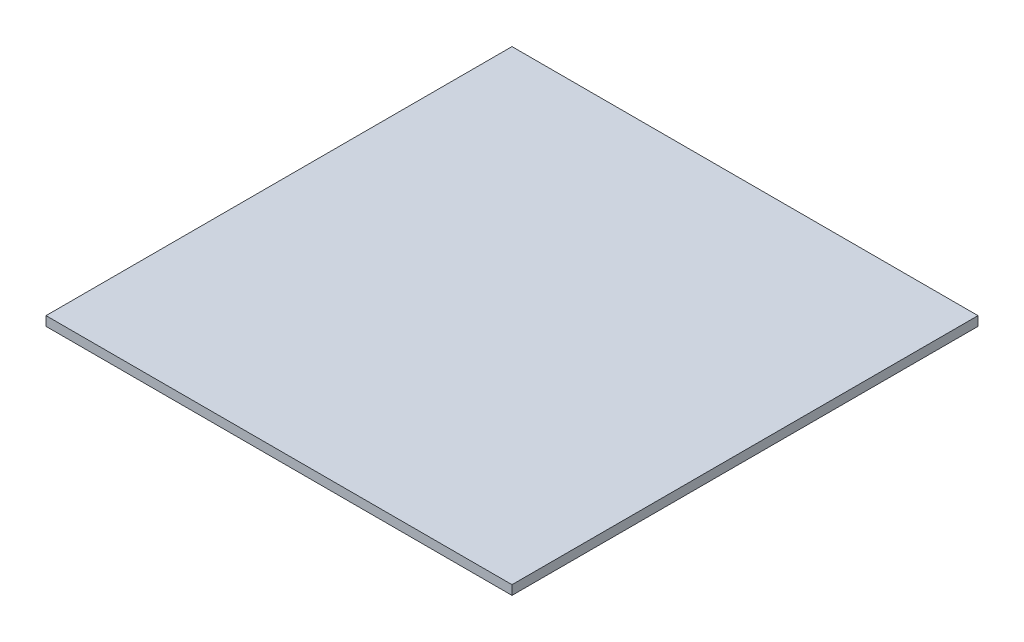
from build123d import *

# Parameters (mm, degrees)
SKETCH_1_W      = 1000
SKETCH_1_H      = 1000
EXTRUDE_1_DEPTH = 20


with BuildPart() as part:
    # 草图1 → 凸台-拉伸1 (new body)
    with BuildSketch(Plane(origin=(0, 0, 0), x_dir=(1, 0, 0), z_dir=(0, 1, 0))):
        Rectangle(SKETCH_1_W, SKETCH_1_H)
    extrude(amount=EXTRUDE_1_DEPTH)


solid = part.part
